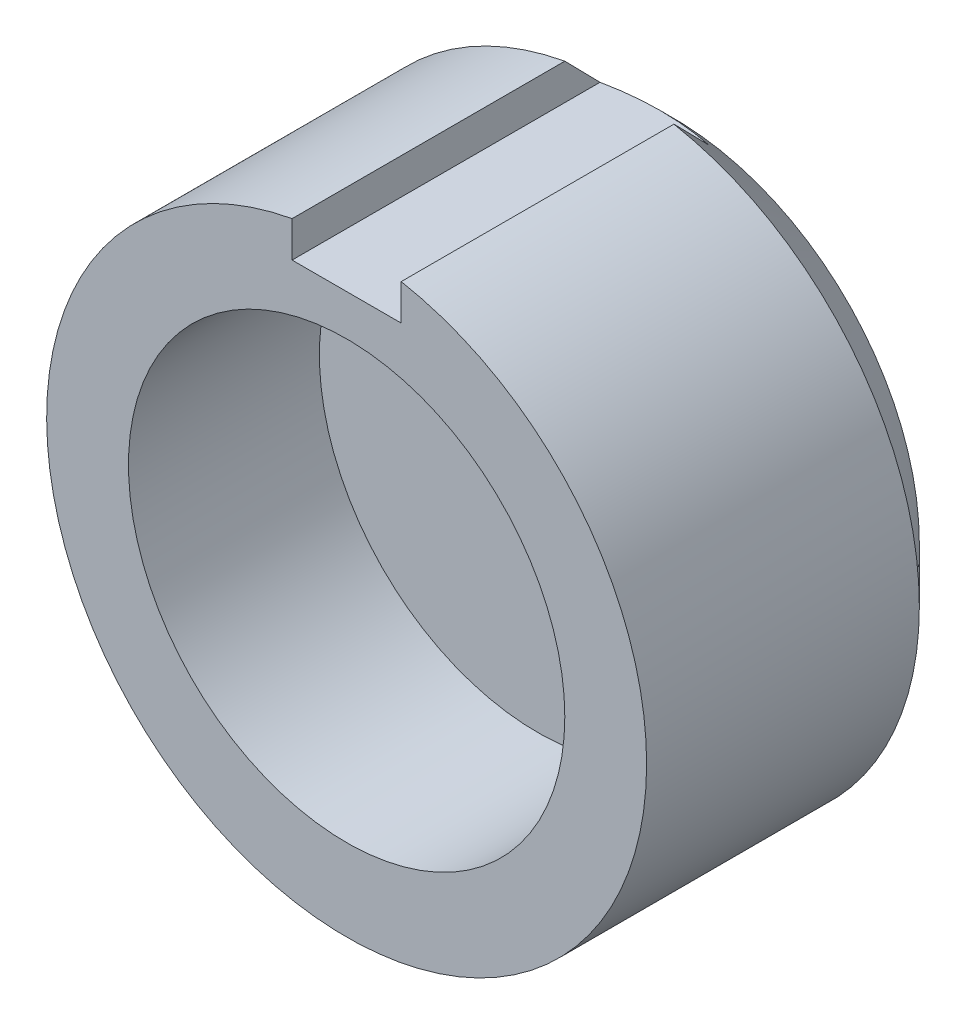
from build123d import *

# Parameters (mm, degrees)
SKETCH1_R           = 11
BOSS_EXTRUDE1_DEPTH = 12
SKETCH2_R           = 8
CUT_EXTRUDE1_DEPTH  = 7
CHAMFER1_SIZE       = 2
SKETCH3_W           = 4
SKETCH3_H           = 3.288893808
CUT_EXTRUDE2_DEPTH  = 22


with BuildPart() as part:
    # Sketch1 → Boss-Extrude1 (new body)
    with BuildSketch(Plane.XY):
        Circle(SKETCH1_R)
    extrude(amount=BOSS_EXTRUDE1_DEPTH)

    # Sketch2 → Cut-Extrude1 (cut)
    with BuildSketch(Plane.XY.offset(12)):
        Circle(SKETCH2_R)
    extrude(amount=-CUT_EXTRUDE1_DEPTH, mode=Mode.SUBTRACT)

    # Chamfer1
    chamfer1_edges = [part.edges().sort_by_distance(p)[0] for p in [
        (-11, 0, 0),
    ]]
    chamfer(chamfer1_edges, length=CHAMFER1_SIZE)

    # Sketch3 → Cut-Extrude2 (cut)
    with BuildSketch(Plane.XY.offset(12)):
        with Locations((0, 11.144446904)):
            Rectangle(SKETCH3_W, SKETCH3_H)
    extrude(amount=-CUT_EXTRUDE2_DEPTH, mode=Mode.SUBTRACT)


solid = part.part
